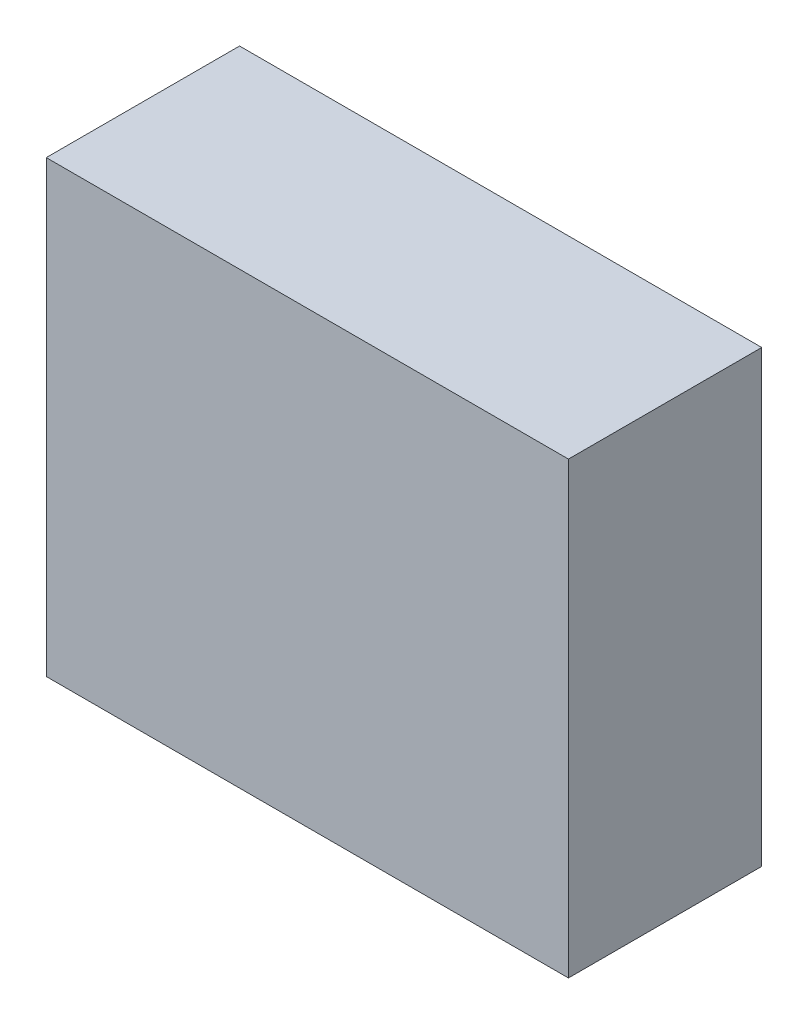
from build123d import *

# Parameters (mm, degrees)
SKETCH1_W           = 54.032082291
SKETCH1_H           = 46.501061971
BOSS_EXTRUDE1_DEPTH = 20


with BuildPart() as part:
    # Sketch1 → Boss-Extrude1 (new body)
    with BuildSketch(Plane.XY):
        with Locations((-5.439070231, 3.466660146)):
            Rectangle(SKETCH1_W, SKETCH1_H)
    extrude(amount=BOSS_EXTRUDE1_DEPTH)


solid = part.part
